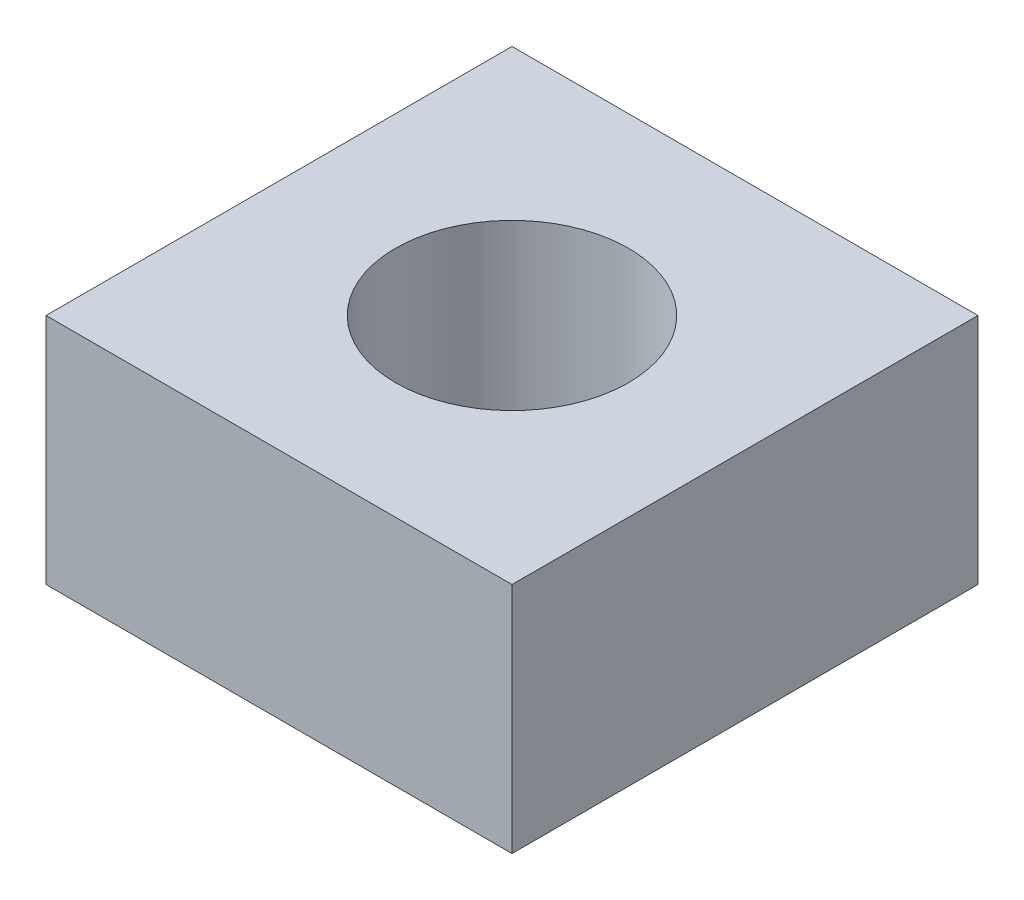
from build123d import *

# Parameters (mm, degrees)
SKETCH1_W           = 20
SKETCH1_H           = 20
SKETCH1_R           = 5
BOSS_EXTRUDE1_DEPTH = 10


with BuildPart() as part:
    # Sketch1 → Boss-Extrude1 (new body)
    with BuildSketch(Plane(origin=(0, 0, 0), x_dir=(1, 0, 0), z_dir=(0, 1, 0))):
        Rectangle(SKETCH1_W, SKETCH1_H)
        Circle(SKETCH1_R, mode=Mode.SUBTRACT)
    extrude(amount=BOSS_EXTRUDE1_DEPTH)


solid = part.part
